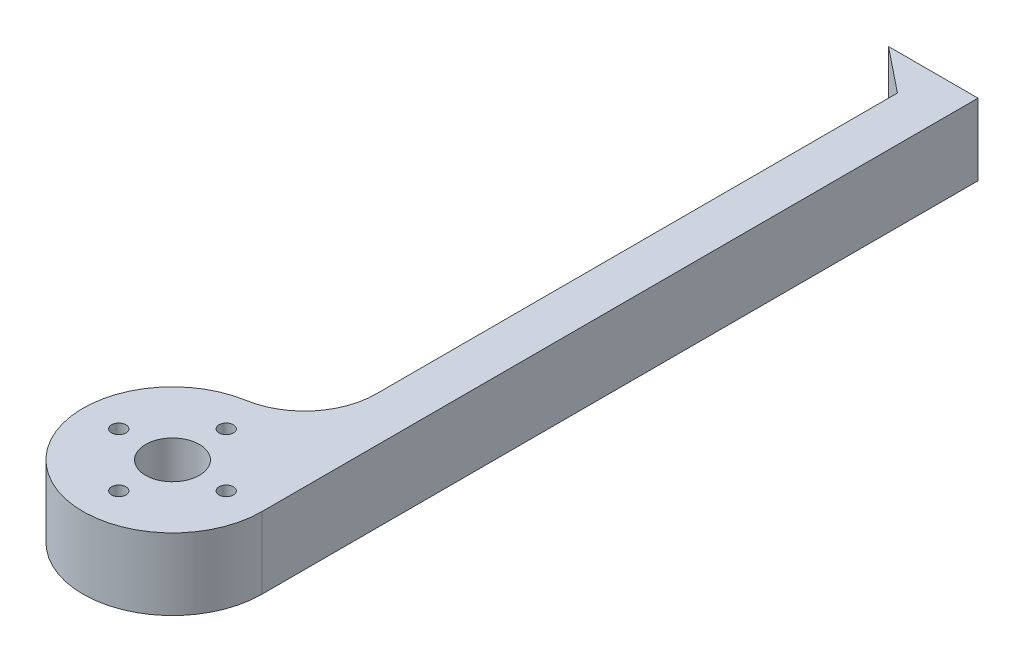
from build123d import *

# Parameters (mm, degrees)
CROQUIS1_R              = 1
SALIENTE_EXTRUIR1_DEPTH = 10
REDONDEO1_R             = 10


with BuildPart() as part:
    # Croquis1 → Saliente-Extruir1 (new body)
    with BuildSketch(Plane(origin=(0, 0, 0), x_dir=(1, 0, 0), z_dir=(0, 1, 0))):
        with BuildLine():
            Line((0, 100), (6.25, 95))
            Line((6.25, 95), (6.25, 10.825317547))
            ThreePointArc((6.25, 10.825317547), (10.825317547, 6.25), (12.5, 0))
            Line((12.5, 0), (12.5, 100))
            Line((12.5, 100), (0, 100))
        make_face()
        with BuildLine():
            ThreePointArc((12.5, 0), (10.825317547, 6.25), (6.25, 10.825317547))
            Line((6.25, 10.825317547), (6.25, 0))
            Line((6.25, 0), (6.5, 0))
            ThreePointArc((6.5, 0), (7.5, 1), (8.5, 0))
            Line((8.5, 0), (12.5, 0))
        make_face()
        with BuildLine():
            Line((6.25, 0), (6.25, 10.825317547))
            ThreePointArc((6.25, 10.825317547), (3.235238064, 12.074072829), (0, 12.5))
            Line((0, 12.5), (0, 8.5))
            ThreePointArc((0, 8.5), (0.707106781, 8.207106781), (1, 7.5))
            ThreePointArc((1, 7.5), (0.707106781, 6.792893219), (0, 6.5))
            Line((0, 6.5), (0, 3.75))
            ThreePointArc((0, 3.75), (2.651650429, 2.651650429), (3.75, 0))
            Line((3.75, 0), (6.25, 0))
        make_face()
        with BuildLine():
            Line((0, 8.5), (0, 12.5))
            ThreePointArc((0, 12.5), (-8.838834765, -8.838834765), (12.5, 0))
            Line((12.5, 0), (8.5, 0))
            ThreePointArc((8.5, 0), (7.5, -1), (6.5, 0))
            Line((6.5, 0), (6.25, 0))
            Line((6.25, 0), (3.75, 0))
            ThreePointArc((3.75, 0), (-2.651650429, -2.651650429), (0, 3.75))
            Line((0, 3.75), (0, 6.5))
            ThreePointArc((0, 6.5), (-1, 7.5), (0, 8.5))
        make_face()
        with Locations((-7.5, 0)):
            Circle(CROQUIS1_R, mode=Mode.SUBTRACT)
        with Locations((0, -7.5)):
            Circle(CROQUIS1_R, mode=Mode.SUBTRACT)
    extrude(amount=SALIENTE_EXTRUIR1_DEPTH)

    # Redondeo1
    redondeo1_edges = [part.edges().sort_by_distance(p)[0] for p in [
        (6.25, 5, -10.825317547),
    ]]
    fillet(redondeo1_edges, radius=REDONDEO1_R)


solid = part.part
